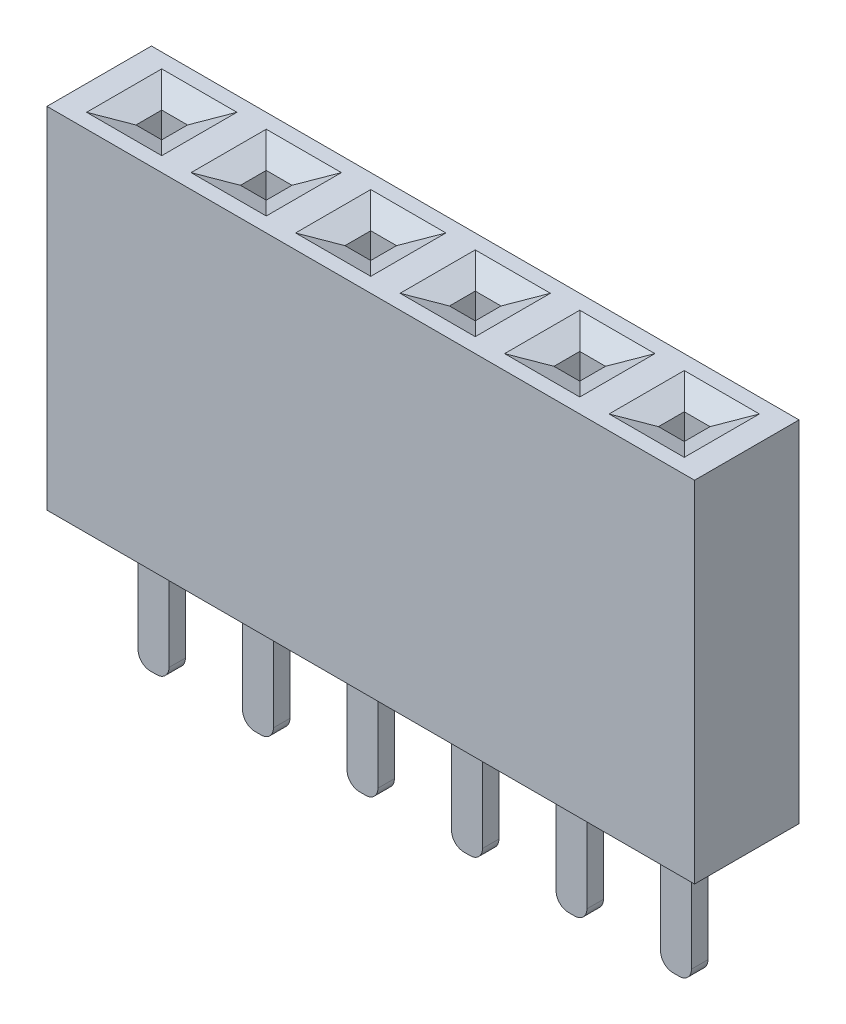
from build123d import *

# Parameters (mm, degrees)
ESQUISSE1_W             = 15.74
ESQUISSE1_H             = 2.54
BOSS_EXTRU_1_DEPTH      = 8.5
ESQUISSE3_W             = 0.626711562
ESQUISSE3_H             = 0.626711562
ENL_V_MAT_EXTRU_3_DEPTH = 8
CHANFREIN3_SIZE         = 0.6
CHANFREIN3_SIZE2        = 0.267137211
ESQUISSE6_W             = 0.75
ESQUISSE6_H             = 0.4
BOSS_EXTRU_3_DEPTH      = 3.2
CONG_1_R                = 0.3


with BuildPart() as part:
    # Esquisse1 → Boss.-Extru.1 (new body)
    with BuildSketch(Plane(origin=(0, 0, 0), x_dir=(1, 0, 0), z_dir=(0, 1, 0))):
        Rectangle(ESQUISSE1_W, ESQUISSE1_H)
    extrude(amount=BOSS_EXTRU_1_DEPTH)

    # Esquisse3 → Enlèv. mat.-Extru.3 (cut)
    with BuildSketch(Plane(origin=(0, 8.5, 0), x_dir=(1, 0, 0), z_dir=(0, 1, 0))):
        with Locations((-6.35, 0)):
            Rectangle(ESQUISSE3_W, ESQUISSE3_H)
        with Locations((-3.81, 0)):
            Rectangle(ESQUISSE3_W, ESQUISSE3_H)
        with Locations((-1.27, 0)):
            Rectangle(ESQUISSE3_W, ESQUISSE3_H)
        with Locations((1.27, 0)):
            Rectangle(ESQUISSE3_W, ESQUISSE3_H)
        with Locations((3.81, 0)):
            Rectangle(ESQUISSE3_W, ESQUISSE3_H)
        with Locations((6.35, 0)):
            Rectangle(ESQUISSE3_W, ESQUISSE3_H)
    extrude(amount=-ENL_V_MAT_EXTRU_3_DEPTH, mode=Mode.SUBTRACT)

    # Chanfrein3
    chanfrein3_edges = [part.edges().sort_by_distance(p)[0] for p in [
        (-3.81, 8.5, -0.313355781),
        (-3.496644219, 8.5, 0),
        (-4.123355781, 8.5, 0),
        (-3.81, 8.5, 0.313355781),
        (-6.35, 8.5, -0.313355781),
        (-6.036644219, 8.5, 0),
        (-6.663355781, 8.5, 0),
        (-6.35, 8.5, 0.313355781),
        (3.81, 8.5, -0.313355781),
        (4.123355781, 8.5, 0),
        (3.496644219, 8.5, 0),
        (3.81, 8.5, 0.313355781),
        (1.27, 8.5, -0.313355781),
        (1.583355781, 8.5, 0),
        (0.956644219, 8.5, 0),
        (1.27, 8.5, 0.313355781),
        (-1.27, 8.5, -0.313355781),
        (-0.956644219, 8.5, 0),
        (-1.583355781, 8.5, 0),
        (-1.27, 8.5, 0.313355781),
        (6.35, 8.5, -0.313355781),
        (6.663355781, 8.5, 0),
        (6.036644219, 8.5, 0),
        (6.35, 8.5, 0.313355781),
    ]]
    chanfrein3_side = [part.faces().sort_by_distance(p)[0] for p in [
        (0, 8.5, 0),
    ]]
    chamfer(chanfrein3_edges, length=CHANFREIN3_SIZE, length2=CHANFREIN3_SIZE2, reference=chanfrein3_side[0])

    # Esquisse6 → Boss.-Extru.3 (add)
    with BuildSketch(Plane.XZ):
        with Locations((-6.35, 0)):
            Rectangle(ESQUISSE6_W, ESQUISSE6_H)
        with Locations((-3.81, 0)):
            Rectangle(ESQUISSE6_W, ESQUISSE6_H)
        with Locations((-1.27, 0)):
            Rectangle(ESQUISSE6_W, ESQUISSE6_H)
        with Locations((1.27, 0)):
            Rectangle(ESQUISSE6_W, ESQUISSE6_H)
        with Locations((3.81, 0)):
            Rectangle(ESQUISSE6_W, ESQUISSE6_H)
        with Locations((6.35, 0)):
            Rectangle(ESQUISSE6_W, ESQUISSE6_H)
    extrude(amount=BOSS_EXTRU_3_DEPTH)

    # Congé1
    cong_1_edges = [part.edges().sort_by_distance(p)[0] for p in [
        (-5.975, -3.2, 0),
        (-6.725, -3.2, 0),
        (-3.435, -3.2, 0),
        (-4.185, -3.2, 0),
        (-0.895, -3.2, 0),
        (-1.645, -3.2, 0),
        (1.645, -3.2, 0),
        (0.895, -3.2, 0),
        (4.185, -3.2, 0),
        (3.435, -3.2, 0),
        (6.725, -3.2, 0),
        (5.975, -3.2, 0),
    ]]
    fillet(cong_1_edges, radius=CONG_1_R)


solid = part.part
